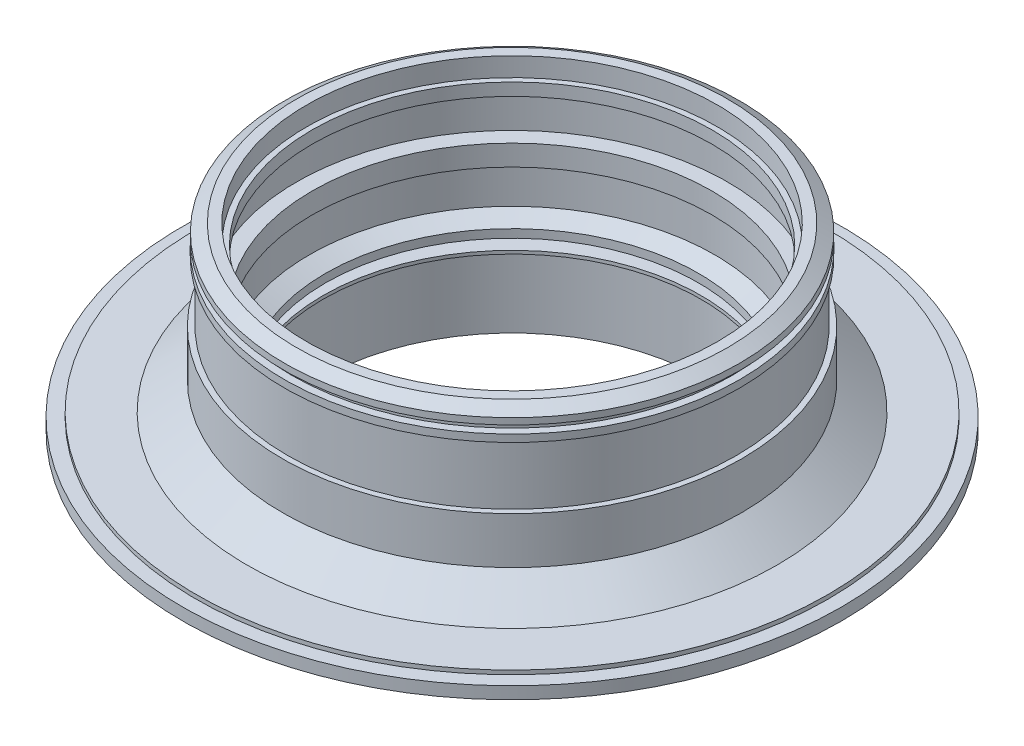
from build123d import *


with BuildPart() as part:
    # Sketch2 → Revolve1 (revolve)
    with BuildSketch(Plane.XY):
        Polygon((-117, 0), (-98.142287974, 0), (-85, 10.210436502), (-85, 27.501263708), (-83, 27.501263708), (-83, 49.793455931), (-84.256609276, 49.793455931), (-84.256609276, 52.5), (-81.542630117, 52.5), (-81.542630117, 55.363879954), (-84.210889447, 55.363879954), (-84.210889447, 57.708994813), (-79.768205673, 60.5), (-75.979278114, 60.5), (-75.979278114, 53.479264493), (-74, 53.479264493), (-74, 48.88455903), (-79.768205673, 48.88455903), (-79.768205673, 33.88455903), (-74, 33.88455903), (-74, 26.204482528), (-75, 26.204482528), (-75, 12.93545297), (-69, 10.000926501), (-69, 6.929678014), (-75.818813089, 4.447833016), (-75.818813089, 2.344727047), (-70, 2.344727047), (-70, 1.144727047), (-71, 1.144727047), (-71, -24.879740451), (-77.75, -24.879740451), (-77.75, -17.379740451), (-74.5, -17.379740451), (-74.5, -2.65), (-80.647227673, -2.65), (-87.5, -9.277608288), (-87.5, -12), (-93.5, -12), (-93.5, -6), (-122, -6), (-122, -1.5), (-117, -1.5), align=None)
    revolve(axis=Axis((0, -27.768010488, 0), (0, 1, 0)))


solid = part.part
